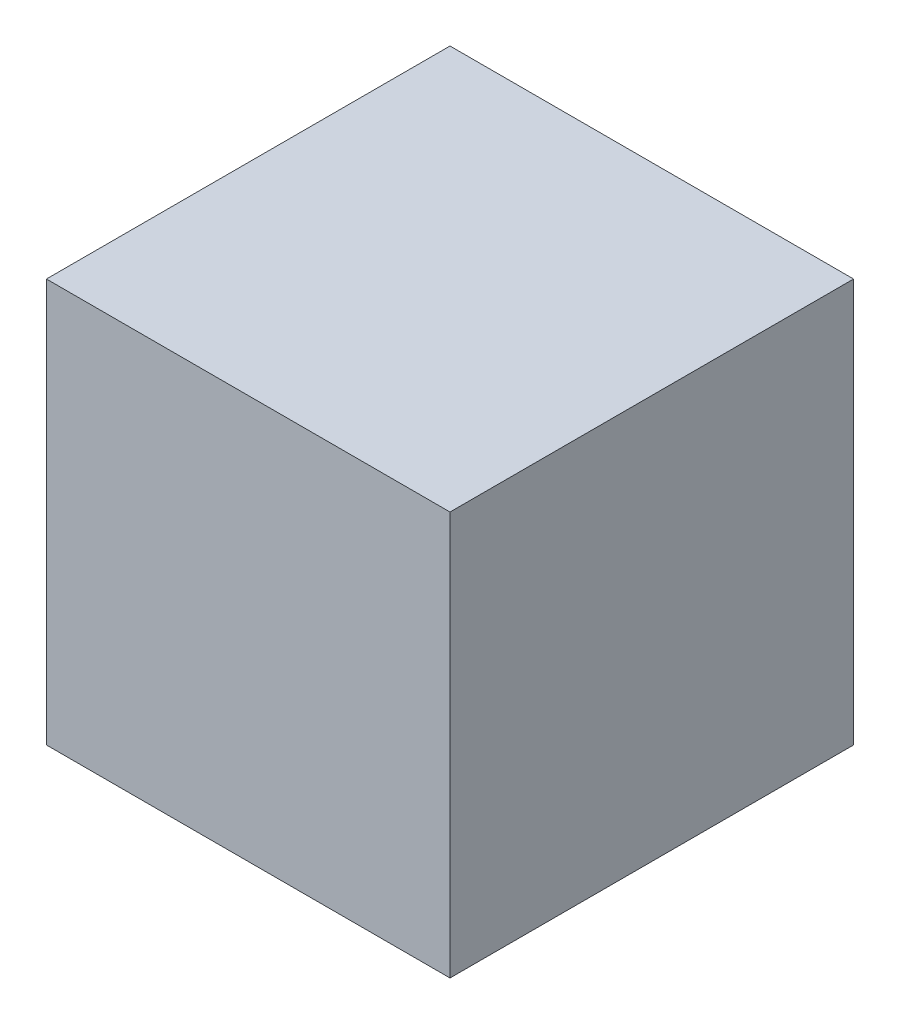
from build123d import *

# Parameters (mm, degrees)
SKETCH1_W           = 10
SKETCH1_H           = 10
BOSS_EXTRUDE1_DEPTH = 10


with BuildPart() as part:
    # Sketch1 → Boss-Extrude1 (new body)
    with BuildSketch(Plane.XY):
        Rectangle(SKETCH1_W, SKETCH1_H)
    extrude(amount=BOSS_EXTRUDE1_DEPTH)


solid = part.part
